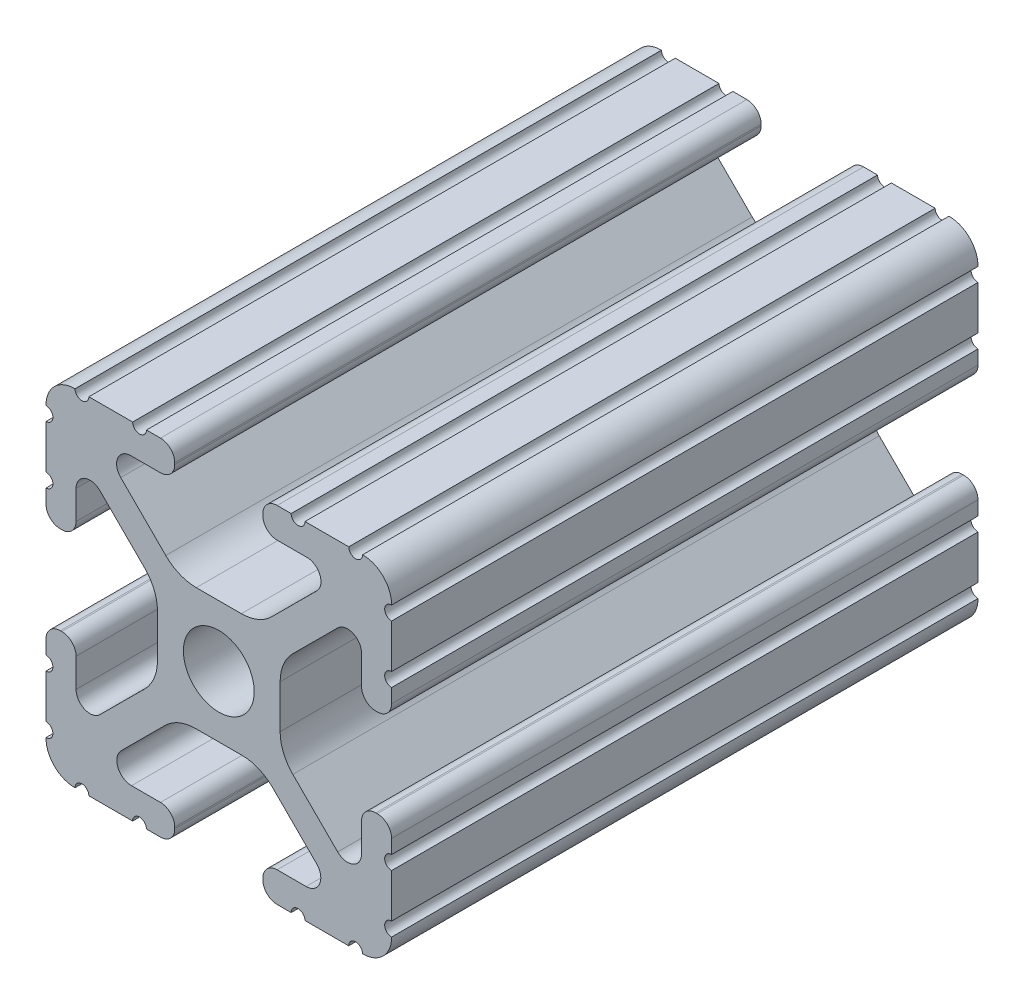
from build123d import *

# Parameters (mm, degrees)
SKETCH1_R           = 2.6035
BOSS_EXTRUDE1_DEPTH = 21.55


with BuildPart() as part:
    # Sketch1 → Boss-Extrude1 (new body, symmetric)
    with BuildSketch(Plane.XY):
        with BuildLine():
            Line((-7.179650497, -8.645192506), (-3.952270251, -5.423690499))
            ThreePointArc((-3.952270251, -5.423690499), (-2.922936451, -4.736929036), (-1.709253557, -4.4958))
            Line((-1.709253557, -4.4958), (1.709253557, -4.4958))
            ThreePointArc((1.709253557, -4.4958), (2.922936451, -4.736929036), (3.952270251, -5.423690499))
            Line((3.952270251, -5.423690499), (7.179650497, -8.645192506))
            ThreePointArc((7.179650497, -8.645192506), (7.41473083, -9.822813117), (6.416408329, -10.4902))
            Line((6.416408329, -10.4902), (4.287512407, -10.4902))
            ThreePointArc((4.287512407, -10.4902), (3.54574862, -10.79744862), (3.2385, -11.539212407))
            Line((3.2385, -11.539212407), (3.2385, -11.650987593))
            ThreePointArc((3.2385, -11.650987593), (3.54574862, -12.39275138), (4.287512407, -12.7))
            Line((4.287512407, -12.7), (5.317126718, -12.7))
            ThreePointArc((5.317126718, -12.7), (5.825126718, -12.192), (6.333126718, -12.7))
            Line((6.333126718, -12.7), (9.550443118, -12.7))
            ThreePointArc((9.550443118, -12.7), (10.058366869, -12.192000006), (10.566443095, -12.699847501))
            ThreePointArc((10.566443095, -12.699847501), (12.082537762, -12.08250727), (12.699846982, -10.566399977))
            ThreePointArc((12.699846982, -10.566399977), (12.192000006, -10.058323491), (12.7, -9.5504))
            Line((12.7, -9.5504), (12.7, -6.3330836))
            ThreePointArc((12.7, -6.3330836), (12.192, -5.8250836), (12.7, -5.3170836))
            Line((12.7, -5.3170836), (12.7, -4.287469289))
            ThreePointArc((12.7, -4.287469289), (12.39275138, -3.545705502), (11.650987593, -3.238456882))
            Line((11.650987593, -3.238456882), (11.539212407, -3.238456882))
            ThreePointArc((11.539212407, -3.238456882), (10.79744862, -3.545705502), (10.4902, -4.287469289))
            Line((10.4902, -4.287469289), (10.4902, -6.402089023))
            ThreePointArc((10.4902, -6.402089023), (9.856505071, -7.351067942), (8.737131347, -7.129408934))
            Line((8.737131347, -7.129408934), (5.441005833, -3.840816462))
            ThreePointArc((5.441005833, -3.840816462), (4.750877967, -2.809883091), (4.5085, -1.593185507))
            Line((4.5085, -1.593185507), (4.5085, 1.593185507))
            ThreePointArc((4.5085, 1.593185507), (4.750877967, 2.809883091), (5.441005833, 3.840816462))
            Line((5.441005833, 3.840816462), (8.737131347, 7.129408934))
            ThreePointArc((8.737131347, 7.129408934), (9.856505071, 7.351067942), (10.4902, 6.402089023))
            Line((10.4902, 6.402089023), (10.4902, 4.287469289))
            ThreePointArc((10.4902, 4.287469289), (10.79744862, 3.545705502), (11.539212407, 3.238456882))
            Line((11.539212407, 3.238456882), (11.650987593, 3.238456882))
            ThreePointArc((11.650987593, 3.238456882), (12.39275138, 3.545705502), (12.7, 4.287469289))
            Line((12.7, 4.287469289), (12.7, 5.3170836))
            ThreePointArc((12.7, 5.3170836), (12.192, 5.8250836), (12.7, 6.3330836))
            Line((12.7, 6.3330836), (12.7, 9.5504))
            ThreePointArc((12.7, 9.5504), (12.192000006, 10.058323491), (12.699846982, 10.566399977))
            ThreePointArc((12.699846982, 10.566399977), (12.082537762, 12.08250727), (10.566443095, 12.699847501))
            ThreePointArc((10.566443095, 12.699847501), (10.058366869, 12.192000006), (9.550443118, 12.7))
            Line((9.550443118, 12.7), (6.333126718, 12.7))
            ThreePointArc((6.333126718, 12.7), (5.825126718, 12.192), (5.317126718, 12.7))
            Line((5.317126718, 12.7), (4.287512407, 12.7))
            ThreePointArc((4.287512407, 12.7), (3.54574862, 12.39275138), (3.2385, 11.650987593))
            Line((3.2385, 11.650987593), (3.2385, 11.539212407))
            ThreePointArc((3.2385, 11.539212407), (3.54574862, 10.79744862), (4.287512407, 10.4902))
            Line((4.287512407, 10.4902), (6.476788598, 10.4902))
            ThreePointArc((6.476788598, 10.4902), (7.432222385, 9.85140422), (7.207036008, 8.724370562))
            Line((7.207036008, 8.724370562), (3.898272566, 5.423169045))
            ThreePointArc((3.898272566, 5.423169045), (2.869120213, 4.736787962), (1.655778399, 4.4958))
            Line((1.655778399, 4.4958), (-1.655778399, 4.4958))
            ThreePointArc((-1.655778399, 4.4958), (-2.869120213, 4.736787962), (-3.898272566, 5.423169045))
            Line((-3.898272566, 5.423169045), (-7.207036008, 8.724370562))
            ThreePointArc((-7.207036008, 8.724370562), (-7.432222385, 9.85140422), (-6.476788598, 10.4902))
            Line((-6.476788598, 10.4902), (-4.287512407, 10.4902))
            ThreePointArc((-4.287512407, 10.4902), (-3.54574862, 10.79744862), (-3.2385, 11.539212407))
            Line((-3.2385, 11.539212407), (-3.2385, 11.650987593))
            ThreePointArc((-3.2385, 11.650987593), (-3.54574862, 12.39275138), (-4.287512407, 12.7))
            Line((-4.287512407, 12.7), (-5.317126718, 12.7))
            ThreePointArc((-5.317126718, 12.7), (-5.825126718, 12.192), (-6.333126718, 12.7))
            Line((-6.333126718, 12.7), (-9.550443118, 12.7))
            ThreePointArc((-9.550443118, 12.7), (-10.058366869, 12.192000006), (-10.566443095, 12.699847501))
            ThreePointArc((-10.566443095, 12.699847501), (-12.082537762, 12.08250727), (-12.699846982, 10.566399977))
            ThreePointArc((-12.699846982, 10.566399977), (-12.192000006, 10.058323491), (-12.7, 9.5504))
            Line((-12.7, 9.5504), (-12.7, 6.3330836))
            ThreePointArc((-12.7, 6.3330836), (-12.192, 5.8250836), (-12.7, 5.3170836))
            Line((-12.7, 5.3170836), (-12.7, 4.287469289))
            ThreePointArc((-12.7, 4.287469289), (-12.39275138, 3.545705502), (-11.650987593, 3.238456882))
            Line((-11.650987593, 3.238456882), (-11.539212407, 3.238456882))
            ThreePointArc((-11.539212407, 3.238456882), (-10.79744862, 3.545705502), (-10.4902, 4.287469289))
            Line((-10.4902, 4.287469289), (-10.4902, 6.402089023))
            ThreePointArc((-10.4902, 6.402089023), (-9.856505071, 7.351067942), (-8.737131347, 7.129408934))
            Line((-8.737131347, 7.129408934), (-5.441005833, 3.840816462))
            ThreePointArc((-5.441005833, 3.840816462), (-4.750877967, 2.809883091), (-4.5085, 1.593185507))
            Line((-4.5085, 1.593185507), (-4.5085, -1.593185507))
            ThreePointArc((-4.5085, -1.593185507), (-4.750877967, -2.809883091), (-5.441005833, -3.840816462))
            Line((-5.441005833, -3.840816462), (-8.737131347, -7.129408934))
            ThreePointArc((-8.737131347, -7.129408934), (-9.856505071, -7.351067942), (-10.4902, -6.402089023))
            Line((-10.4902, -6.402089023), (-10.4902, -4.287469289))
            ThreePointArc((-10.4902, -4.287469289), (-10.79744862, -3.545705502), (-11.539212407, -3.238456882))
            Line((-11.539212407, -3.238456882), (-11.650987593, -3.238456882))
            ThreePointArc((-11.650987593, -3.238456882), (-12.39275138, -3.545705502), (-12.7, -4.287469289))
            Line((-12.7, -4.287469289), (-12.7, -5.3170836))
            ThreePointArc((-12.7, -5.3170836), (-12.192, -5.8250836), (-12.7, -6.3330836))
            Line((-12.7, -6.3330836), (-12.7, -9.5504))
            ThreePointArc((-12.7, -9.5504), (-12.192000006, -10.058323491), (-12.699846982, -10.566399977))
            ThreePointArc((-12.699846982, -10.566399977), (-12.082537762, -12.08250727), (-10.566443095, -12.699847501))
            ThreePointArc((-10.566443095, -12.699847501), (-10.058366869, -12.192000006), (-9.550443118, -12.7))
            Line((-9.550443118, -12.7), (-6.333126718, -12.7))
            ThreePointArc((-6.333126718, -12.7), (-5.825126718, -12.192), (-5.317126718, -12.7))
            Line((-5.317126718, -12.7), (-4.287512407, -12.7))
            ThreePointArc((-4.287512407, -12.7), (-3.54574862, -12.39275138), (-3.2385, -11.650987593))
            Line((-3.2385, -11.650987593), (-3.2385, -11.539212407))
            ThreePointArc((-3.2385, -11.539212407), (-3.54574862, -10.79744862), (-4.287512407, -10.4902))
            Line((-4.287512407, -10.4902), (-6.416408329, -10.4902))
            ThreePointArc((-6.416408329, -10.4902), (-7.41473083, -9.822813117), (-7.179650497, -8.645192506))
        make_face()
        Circle(SKETCH1_R, mode=Mode.SUBTRACT)
    extrude(amount=BOSS_EXTRUDE1_DEPTH, both=True)


solid = part.part
